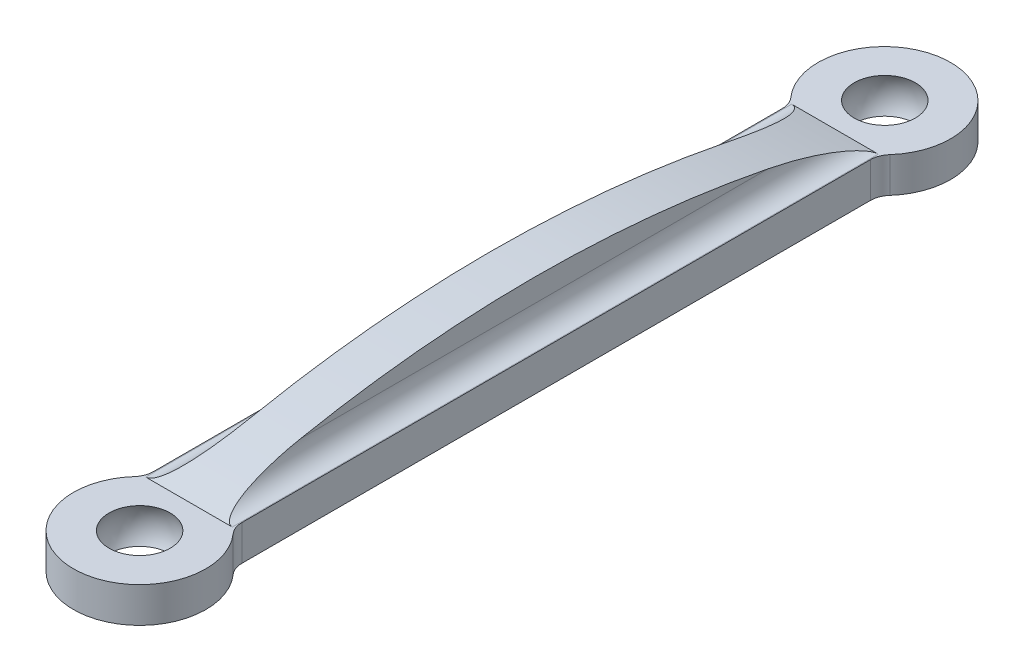
from build123d import *

# Parameters (mm, degrees)
SKETCH1_R           = 1.5875
BOSS_EXTRUDE1_DEPTH = 1.27
BOSS_EXTRUDE2_DEPTH = 1.5875
FILLET1_R           = 1.524


with BuildPart() as part:
    # Sketch1 → Boss-Extrude1 (new body, symmetric)
    with BuildSketch(Plane(origin=(0, 0, 0), x_dir=(1, 0, 0), z_dir=(0, 1, 0))):
        with BuildLine():
            Line((-3.175, 3.549757914), (-3.175, 49.993442086))
            ThreePointArc((-3.175, 49.993442086), (0, 58.3057), (3.175, 49.993442086))
            Line((3.175, 49.993442086), (3.175, 3.549757914))
            ThreePointArc((3.175, 3.549757914), (0, -4.7625), (-3.175, 3.549757914))
        make_face()
        Circle(SKETCH1_R, mode=Mode.SUBTRACT)
        with Locations((0, 53.5432)):
            Circle(SKETCH1_R, mode=Mode.SUBTRACT)
    extrude(amount=BOSS_EXTRUDE1_DEPTH, both=True)

    # Sketch2 → Cut-Revolve1 (revolve, cut)
    with BuildSketch(Plane(origin=(0, 0, 0), x_dir=(0, 0, -1), z_dir=(1, 0, 0))):
        with BuildLine():
            Line((0, -2.54), (0, 2.54))
            ThreePointArc((0, 2.54), (2.54, 0), (0, -2.54))
        make_face()
    revolve(axis=Axis((0, -2.54, 0), (0, 1, 0)), mode=Mode.SUBTRACT)

    # Sketch3 → Cut-Revolve2 (revolve, cut)
    with BuildSketch(Plane(origin=(0, 0, 0), x_dir=(0, 0, -1), z_dir=(1, 0, 0))):
        with BuildLine():
            Line((53.574492193, -2.54), (53.574492193, 2.54))
            ThreePointArc((53.574492193, 2.54), (51.034492193, 0), (53.574492193, -2.54))
        make_face()
    revolve(axis=Axis((0, 8.508702539, -53.574492193), (0, -1, 0)), mode=Mode.SUBTRACT)

    # Sketch5 → Boss-Extrude2 (add, symmetric)
    with BuildSketch(Plane(origin=(0, 0, 0), x_dir=(0, 0, -1), z_dir=(1, 0, 0))):
        with BuildLine():
            Line((3.549757914, 1.27), (49.993442086, 1.27))
            ThreePointArc((49.993442086, 1.27), (26.7716, 4.445), (3.549757914, 1.27))
        make_face()
    extrude(amount=BOSS_EXTRUDE2_DEPTH, both=True)

    # Fillet1
    fillet1_edges = [part.edges().sort_by_distance(p)[0] for p in [
        (-1.5875, 1.27, -26.7716),
        (1.5875, 1.27, -26.7716),
        (-3.175, 0, -3.549757914),
        (-3.175, 0, -49.993442086),
        (3.175, 0, -49.993442086),
        (3.175, 0, -3.549757914),
    ]]
    fillet(fillet1_edges, radius=FILLET1_R)


solid = part.part
